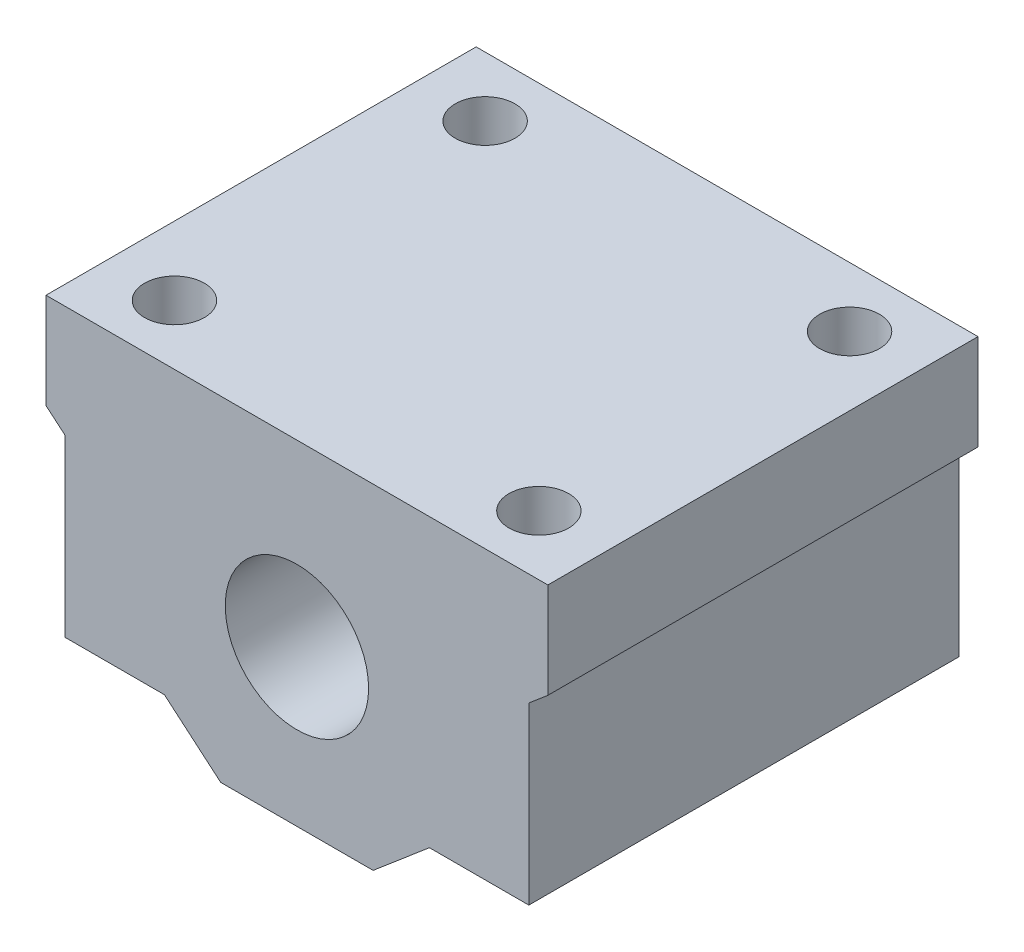
from build123d import *

# Parameters (mm, degrees)
RESSALTO_EXTRUS_O1_DEPTH = 36
ESBO_O2_R                = 6
CORTE_EXTRUS_O1_DEPTH    = 37
ESBO_O4_R                = 2.5
CORTE_EXTRUS_O2_DEPTH    = 29


with BuildPart() as part:
    # Esboço1 → Ressalto-extrusão1 (new body)
    with BuildSketch(Plane.XY):
        Polygon((6.3777561, -6.012123693), (-6.3777561, -6.012123693), (-11.089070113, -2.012123693), (-19.410929887, -2.012123693), (-19.410929887, 12.63872394), (-21, 13.987876307), (-21, 21.987876307), (21, 21.987876307), (21, 13.987876307), (19.410929887, 12.63872394), (19.410929887, -2.012123693), (11.089070113, -2.012123693), align=None)
    extrude(amount=RESSALTO_EXTRUS_O1_DEPTH)

    # Esboço2 → Corte-extrusão1 (cut, through all)
    with BuildSketch(Plane.XY.offset(36)):
        with Locations((0, 6.987876307)):
            Circle(ESBO_O2_R)
    extrude(amount=-CORTE_EXTRUS_O1_DEPTH, mode=Mode.SUBTRACT)

    # Esboço4 → Corte-extrusão2 (cut, through all)
    with BuildSketch(Plane.XZ.offset(6.012123693)):
        with Locations((-15.25, 5)):
            Circle(ESBO_O4_R)
        with Locations((-15.25, 31)):
            Circle(ESBO_O4_R)
        with Locations((15.25, 5)):
            Circle(ESBO_O4_R)
        with Locations((15.25, 31)):
            Circle(ESBO_O4_R)
    extrude(amount=-CORTE_EXTRUS_O2_DEPTH, mode=Mode.SUBTRACT)


solid = part.part
